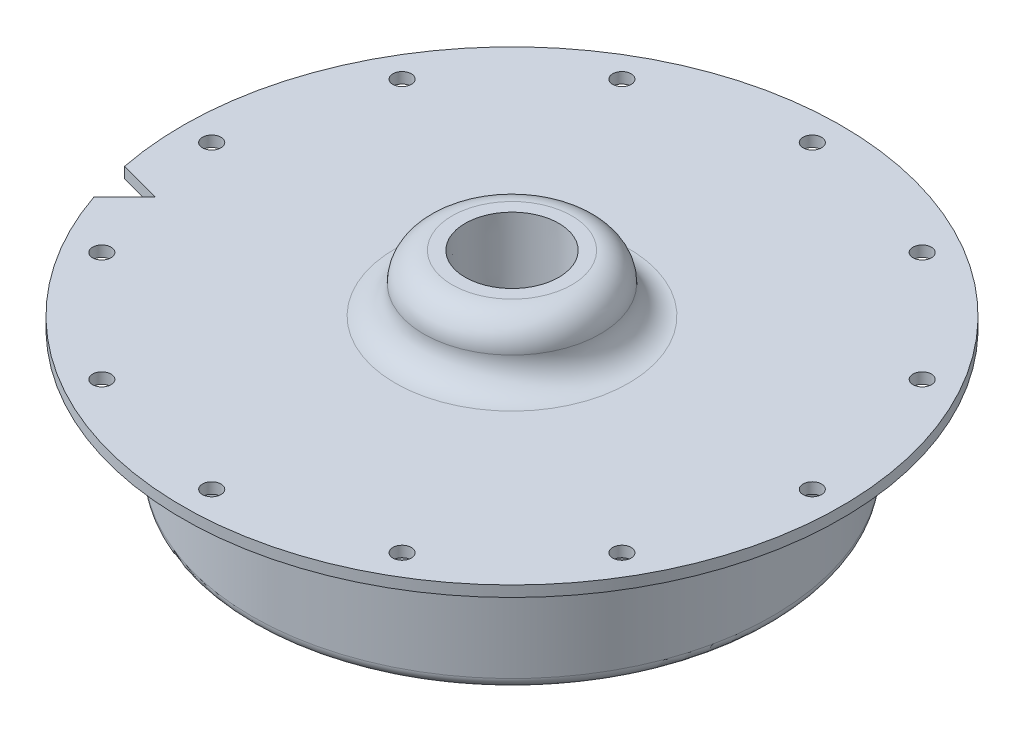
from build123d import *

# Parameters (mm, degrees)
F_36_0_1065_DIAMETER_HOLE1_D = 2.7051
CIRPATTERN1_COUNT            = 12
CUT_EXTRUDE1_DEPTH           = 1.5875


with BuildPart() as part:
    # Sketch1 → Revolve1 (revolve)
    with BuildSketch(Plane.XY):
        with BuildLine():
            Line((-48.26, 0), (-39.6875, 0))
            ThreePointArc((-39.6875, 0), (-38.564967985, -0.464967985), (-38.1, -1.5875))
            Line((-38.1, -1.5875), (-38.1, -17.4625))
            ThreePointArc((-38.1, -17.4625), (-36.5125, -19.05), (-34.925, -17.4625))
            Line((-34.925, -17.4625), (-34.925, -3.175))
            ThreePointArc((-34.925, -3.175), (-33.99506403, -0.92993597), (-31.75, 0))
            Line((-31.75, 0), (-5.588, 0))
            Line((-5.588, 0), (-5.588, 9.906))
            Line((-5.588, 9.906), (-8.763, 9.906))
            ThreePointArc((-8.763, 9.906), (-11.70403388, 8.68778388), (-12.92225, 5.74675))
            ThreePointArc((-12.92225, 5.74675), (-14.14046612, 2.80571612), (-17.0815, 1.5875))
            Line((-17.0815, 1.5875), (-48.26, 1.5875))
            Line((-48.26, 1.5875), (-48.26, 0))
        make_face()
    revolve(axis=Axis((0, 55, 0), (0, -1, 0)))

    # #36 (0.1065) Diameter Hole1 (through all)
    with Locations(Plane(origin=(0, 1.5875, 0), x_dir=(1, 0, 0), z_dir=(0, 1, 0))):
        with Locations((-43.97375, 0)):
            f_36_0_1065_diameter_hole1 = Hole(F_36_0_1065_DIAMETER_HOLE1_D / 2)

    # CirPattern1: #36 (0.1065) Diameter Hole1 ×12 about axis
    cirpattern1_axis = Axis((0, 0, 0), (0, 1, 0))
    for i in range(1, CIRPATTERN1_COUNT):
        add(f_36_0_1065_diameter_hole1.rotate(cirpattern1_axis, i * 360 / CIRPATTERN1_COUNT), mode=Mode.SUBTRACT)

    # Sketch5 → 1/4 NPT Tapped Hole1 (revolve, cut)
    with BuildSketch(Plane(origin=(0, 9.906, 0), x_dir=(0, 0, 1), z_dir=(1, 0, 0))):
        Polygon((0, 0), (0, 28.956), (5.5626, 28.956), (5.5626, 9.906), (6.557984794, 9.906), (6.8545837, 0), align=None)
    revolve(axis=Axis((0, 16.256, 0), (0, -1, 0)), mode=Mode.SUBTRACT)

    # Sketch6 → Cut-Extrude1 (cut)
    with BuildSketch(Plane(origin=(0, 1.5875, 0), x_dir=(1, 0, 0), z_dir=(0, 1, 0))):
        with BuildLine():
            Line((-45.692838455, -15.530361037), (-41.202710394, -11.040232976))
            Line((-41.202710394, -11.040232976), (-47.336339391, -9.39673204))
            ThreePointArc((-47.336339391, -9.39673204), (-46.615580377, -12.490607117), (-45.692838455, -15.530361037))
        make_face()
    extrude(amount=-CUT_EXTRUDE1_DEPTH, mode=Mode.SUBTRACT)


solid = part.part
